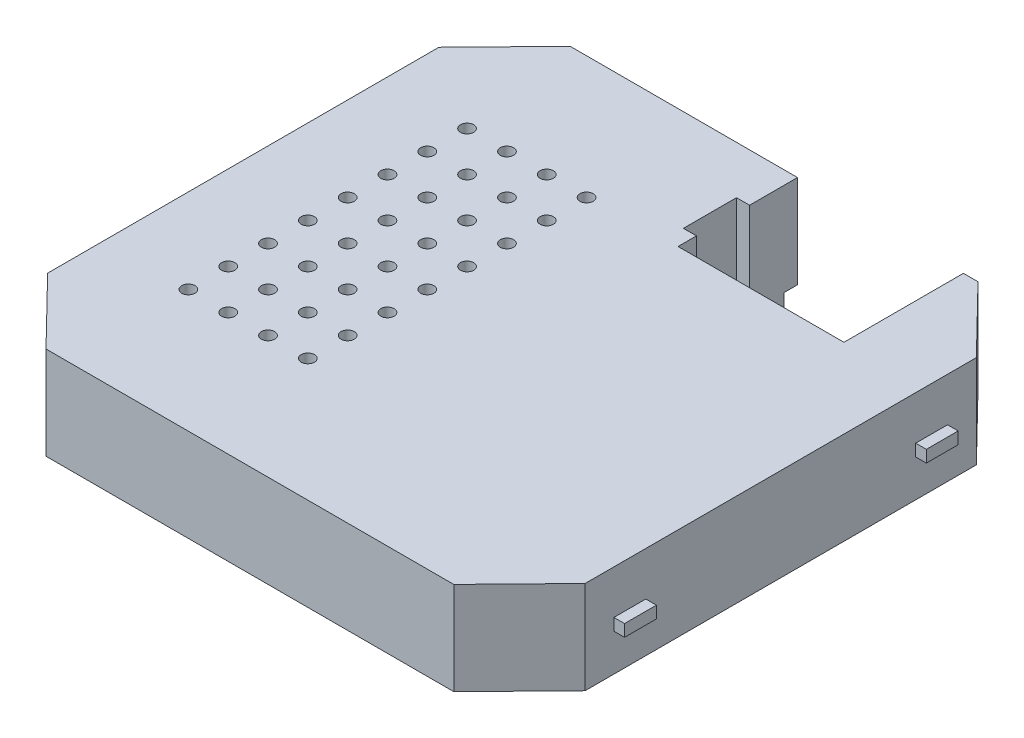
from build123d import *

# Parameters (mm, degrees)
BOSS_EXTRUDE1_DEPTH = 7
CUT_EXTRUDE1_DEPTH  = 6
CUT_EXTRUDE2_DEPTH  = 8
BOSS_EXTRUDE2_DEPTH = 10
SKETCH5_W           = 2.4
SKETCH5_H           = 0.9
BOSS_EXTRUDE3_DEPTH = 0.8
SKETCH6_W           = 2.4
SKETCH6_H           = 0.9
BOSS_EXTRUDE4_DEPTH = 0.8
SKETCH7_R           = 0.5
CUT_EXTRUDE3_DEPTH  = 1


with BuildPart() as part:
    # Sketch1 → Boss-Extrude1 (new body)
    with BuildSketch(Plane(origin=(0, 0, 0), x_dir=(1, 0, 0), z_dir=(0, 1, 0))):
        Polygon((-20.25, 14.738772175), (-15.362506196, 19.75), (15.362506196, 19.75), (20.25, 14.738772175), (20.25, -14.738772175), (15.362506196, -19.75), (-15.362506196, -19.75), (-20.25, -14.738772175), align=None)
    extrude(amount=BOSS_EXTRUDE1_DEPTH)

    # Sketch2 → Cut-Extrude1 (cut)
    with BuildSketch(Plane.XZ):
        Polygon((14.940951585, 18.75), (-14.940951585, 18.75), (-19.25, 14.331861751), (-19.25, -14.331861751), (-14.940951585, -18.75), (14.940951585, -18.75), (19.25, -14.331861751), (19.25, 14.331861751), align=None)
    extrude(amount=-CUT_EXTRUDE1_DEPTH, mode=Mode.SUBTRACT)

    # Sketch3 → Cut-Extrude2 (cut, through all)
    with BuildSketch(Plane(origin=(0, 7, 0), x_dir=(1, 0, 0), z_dir=(0, 1, 0))):
        Polygon((14.262506196, 19.75), (1.762506196, 19.75), (1.762506196, 16.137014737), (0.777606409, 16.137014737), (0.777606409, 12.137014737), (1.762506196, 12.137014737), (1.762506196, 10.75), (14.262506196, 10.75), align=None)
    extrude(amount=-CUT_EXTRUDE2_DEPTH, mode=Mode.SUBTRACT)

    # Sketch4 → Boss-Extrude2 (add)
    with BuildSketch(Plane.XZ.offset(-6)):
        Polygon((0.762506196, -18.75), (1.762506196, -18.75), (1.762506196, -16.137014737), (0.777606409, -16.137014737), (0.777606409, -12.137014737), (1.762506196, -12.137014737), (1.762506196, -10.75), (14.262506196, -10.75), (14.262506196, -18.75), (15.262506196, -18.75), (15.262506196, -9.75), (0.762506196, -9.75), (0.762506196, -11.137014737), (-0.222393591, -11.137014737), (-0.222393591, -17.137014737), (0.762506196, -17.137014737), align=None)
    extrude(amount=BOSS_EXTRUDE2_DEPTH)

    # Sketch5 → Boss-Extrude3 (add)
    with BuildSketch(Plane.ZY.offset(20.25)):
        with Locations((-11.369651621, 3.25)):
            Rectangle(SKETCH5_W, SKETCH5_H)
        with Locations((11.369651621, 3.25)):
            Rectangle(SKETCH5_W, SKETCH5_H)
    extrude(amount=BOSS_EXTRUDE3_DEPTH)

    # Sketch6 → Boss-Extrude4 (add)
    with BuildSketch(Plane(origin=(20.25, 0, 0), x_dir=(0, 0, -1), z_dir=(1, 0, 0))):
        with Locations((-11.369651621, 3.25)):
            Rectangle(SKETCH6_W, SKETCH6_H)
        with Locations((11.369651621, 3.25)):
            Rectangle(SKETCH6_W, SKETCH6_H)
    extrude(amount=BOSS_EXTRUDE4_DEPTH)

    # Sketch7 → Cut-Extrude3 (cut)
    with BuildSketch(Plane(origin=(0, 7, 0), x_dir=(1, 0, 0), z_dir=(0, 1, 0))):
        with Locations((-4.884098743, -10.5)):
            Circle(SKETCH7_R)
        with Locations((-7.884098743, -10.5)):
            Circle(SKETCH7_R)
        with Locations((-10.884098743, -10.5)):
            Circle(SKETCH7_R)
        with Locations((-13.884098743, -10.5)):
            Circle(SKETCH7_R)
        with Locations((-7.884098743, -7.5)):
            Circle(SKETCH7_R)
        with Locations((-10.884098743, -7.5)):
            Circle(SKETCH7_R)
        with Locations((-13.884098743, -7.5)):
            Circle(SKETCH7_R)
        with Locations((-7.884098743, -4.5)):
            Circle(SKETCH7_R)
        with Locations((-10.884098743, -4.5)):
            Circle(SKETCH7_R)
        with Locations((-13.884098743, -4.5)):
            Circle(SKETCH7_R)
        with Locations((-7.884098743, -1.5)):
            Circle(SKETCH7_R)
        with Locations((-10.884098743, -1.5)):
            Circle(SKETCH7_R)
        with Locations((-13.884098743, -1.5)):
            Circle(SKETCH7_R)
        with Locations((-7.884098743, 1.5)):
            Circle(SKETCH7_R)
        with Locations((-10.884098743, 1.5)):
            Circle(SKETCH7_R)
        with Locations((-13.884098743, 1.5)):
            Circle(SKETCH7_R)
        with Locations((-7.884098743, 4.5)):
            Circle(SKETCH7_R)
        with Locations((-10.884098743, 4.5)):
            Circle(SKETCH7_R)
        with Locations((-13.884098743, 4.5)):
            Circle(SKETCH7_R)
        with Locations((-7.884098743, 7.5)):
            Circle(SKETCH7_R)
        with Locations((-10.884098743, 7.5)):
            Circle(SKETCH7_R)
        with Locations((-13.884098743, 7.5)):
            Circle(SKETCH7_R)
        with Locations((-7.884098743, 10.5)):
            Circle(SKETCH7_R)
        with Locations((-10.884098743, 10.5)):
            Circle(SKETCH7_R)
        with Locations((-13.884098743, 10.5)):
            Circle(SKETCH7_R)
        with Locations((-4.884098743, -7.5)):
            Circle(SKETCH7_R)
        with Locations((-4.884098743, -4.5)):
            Circle(SKETCH7_R)
        with Locations((-4.884098743, -1.5)):
            Circle(SKETCH7_R)
        with Locations((-4.884098743, 1.5)):
            Circle(SKETCH7_R)
        with Locations((-4.884098743, 4.5)):
            Circle(SKETCH7_R)
        with Locations((-4.884098743, 7.5)):
            Circle(SKETCH7_R)
        with Locations((-4.884098743, 10.5)):
            Circle(SKETCH7_R)
    extrude(amount=-CUT_EXTRUDE3_DEPTH, mode=Mode.SUBTRACT)


solid = part.part
